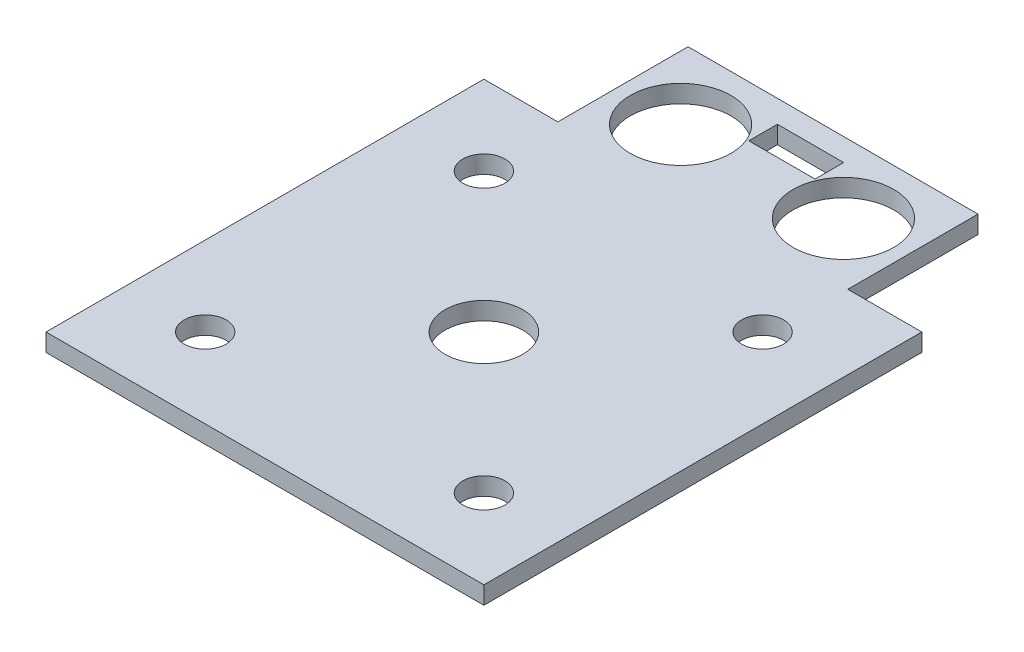
from build123d import *

# Parameters (mm, degrees)
SKETCH1_R           = 21
SKETCH1_R_2         = 20
BOSS_EXTRUDE1_DEPTH = 3.5
SKETCH2_R           = 3.55
SKETCH2_R_2         = 6.55
SKETCH2_R_3         = 8.5
SKETCH2_W           = 11.2
SKETCH2_H           = 4.84
BOSS_EXTRUDE2_DEPTH = 3


with BuildPart() as part:
    # Sketch1 → Boss-Extrude1 (new body)
    with BuildSketch(Plane(origin=(0, 0, 0), x_dir=(1, 0, 0), z_dir=(0, 1, 0))):
        Circle(SKETCH1_R)
        Circle(SKETCH1_R_2, mode=Mode.SUBTRACT)
    extrude(amount=BOSS_EXTRUDE1_DEPTH)

    # Sketch2 → Boss-Extrude2 (add)
    with BuildSketch(Plane(origin=(0, 3.5, 0), x_dir=(1, 0, 0), z_dir=(0, 1, 0))):
        Polygon((-37, 37), (-37, -37), (37, -37), (37, 37), (24.5, 37), (24.5, 59), (-24.5, 59), (-24.5, 37), align=None)
        with Locations((-23.55, -23.55)):
            Circle(SKETCH2_R, mode=Mode.SUBTRACT)
        Circle(SKETCH2_R_2, mode=Mode.SUBTRACT)
        with Locations((23.55, -23.55)):
            Circle(SKETCH2_R, mode=Mode.SUBTRACT)
        with Locations((-23.55, 23.55)):
            Circle(SKETCH2_R, mode=Mode.SUBTRACT)
        with Locations((23.55, 23.55)):
            Circle(SKETCH2_R, mode=Mode.SUBTRACT)
        with Locations((13.76, 47)):
            Circle(SKETCH2_R_3, mode=Mode.SUBTRACT)
        with Locations((-13.76, 47)):
            Circle(SKETCH2_R_3, mode=Mode.SUBTRACT)
        with Locations((0, 52.78)):
            Rectangle(SKETCH2_W, SKETCH2_H, mode=Mode.SUBTRACT)
    extrude(amount=BOSS_EXTRUDE2_DEPTH)


solid = part.part
